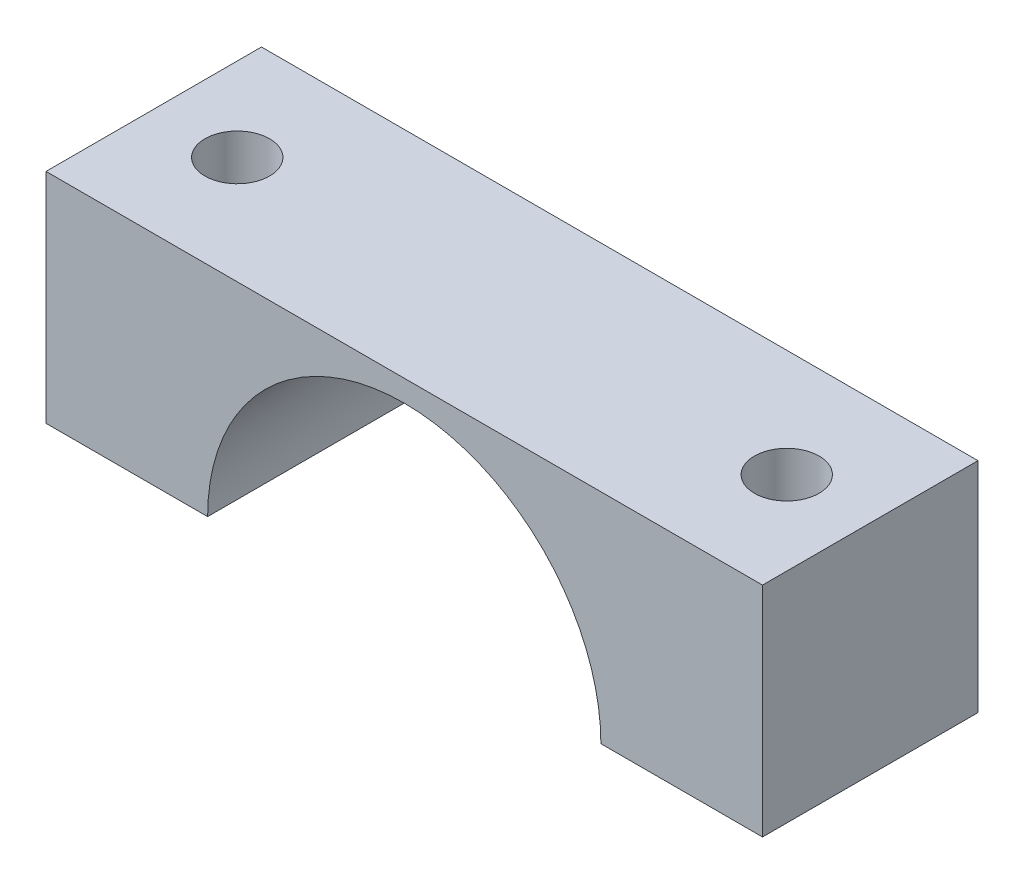
from build123d import *

# Parameters (mm, degrees)
EXTRUDE_1_DEPTH     = 20
SKETCH_2_R          = 3
CUT_EXTRUDE_1_DEPTH = 21.25


with BuildPart() as part:
    # 草图1 → 凸台-拉伸1 (new body)
    with BuildSketch(Plane.XY):
        with BuildLine():
            Line((-33.25, 0), (-18.25, 0))
            ThreePointArc((-18.25, 0), (0, 18.25), (18.25, 0))
            Line((18.25, 0), (33.25, 0))
            Line((33.25, 0), (33.25, 20.25))
            Line((33.25, 20.25), (-33.25, 20.25))
            Line((-33.25, 20.25), (-33.25, 0))
        make_face()
    extrude(amount=EXTRUDE_1_DEPTH)

    # 草图2 → 切除-拉伸1 (cut, through all)
    with BuildSketch(Plane(origin=(0, 20.25, 0), x_dir=(1, 0, 0), z_dir=(0, 1, 0))):
        with Locations((-25.5, -10)):
            Circle(SKETCH_2_R)
        with Locations((25.5, -10)):
            Circle(SKETCH_2_R)
    extrude(amount=-CUT_EXTRUDE_1_DEPTH, mode=Mode.SUBTRACT)


solid = part.part
